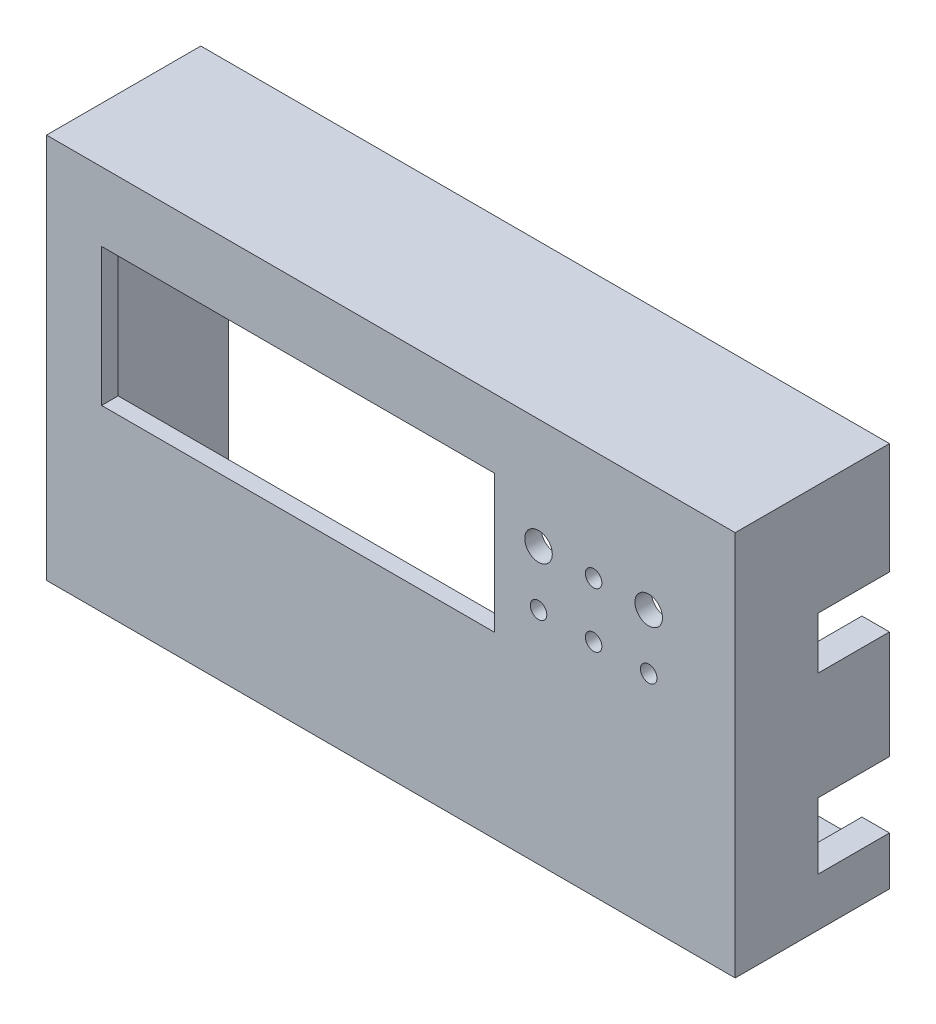
from build123d import *

# Parameters (mm, degrees)
SKETCH1_W           = 125
SKETCH1_H           = 70
BOSS_EXTRUDE1_DEPTH = 3
SKETCH2_W           = 71.3
SKETCH2_H           = 25
CUT_EXTRUDE1_DEPTH  = 5
SKETCH4_R           = 2.5
SKETCH4_R_2         = 1.5
CUT_EXTRUDE2_DEPTH  = 5
SKETCH5_W           = 125
SKETCH5_H           = 70
SKETCH5_W_2         = 115
SKETCH5_H_2         = 60
BOSS_EXTRUDE2_DEPTH = 25
SKETCH6_R           = 2
CUT_EXTRUDE3_DEPTH  = 10
SKETCH7_W           = 13
SKETCH7_H           = 12
SKETCH7_H_2         = 9.422573881
CUT_EXTRUDE4_DEPTH  = 10


with BuildPart() as part:
    # Sketch1 → Boss-Extrude1 (new body)
    with BuildSketch(Plane.XY):
        with Locations((62.5, 35)):
            Rectangle(SKETCH1_W, SKETCH1_H)
    extrude(amount=BOSS_EXTRUDE1_DEPTH)

    # Sketch2 → Cut-Extrude1 (cut)
    with BuildSketch(Plane.XY.offset(3)):
        with Locations((45.65, 45)):
            Rectangle(SKETCH2_W, SKETCH2_H)
    extrude(amount=-CUT_EXTRUDE1_DEPTH, mode=Mode.SUBTRACT)

    # Sketch4 → Cut-Extrude2 (cut)
    with BuildSketch(Plane.XY.offset(3)):
        with Locations((89.3, 50)):
            Circle(SKETCH4_R)
        with Locations((99.3, 50)):
            Circle(SKETCH4_R_2)
        with Locations((109.3, 50)):
            Circle(SKETCH4_R)
        with Locations((89.3, 40)):
            Circle(SKETCH4_R_2)
        with Locations((99.3, 40)):
            Circle(SKETCH4_R_2)
        with Locations((109.3, 40)):
            Circle(SKETCH4_R_2)
    extrude(amount=-CUT_EXTRUDE2_DEPTH, mode=Mode.SUBTRACT)

    # Sketch5 → Boss-Extrude2 (add)
    with BuildSketch(Plane(origin=(0, 0, 0), x_dir=(-1, 0, 0), z_dir=(0, 0, -1))):
        with Locations((-62.5, 35)):
            Rectangle(SKETCH5_W, SKETCH5_H)
        with Locations((-62.5, 35)):
            Rectangle(SKETCH5_W_2, SKETCH5_H_2, mode=Mode.SUBTRACT)
    extrude(amount=BOSS_EXTRUDE2_DEPTH)

    # Sketch6 → Cut-Extrude3 (cut)
    with BuildSketch(Plane(origin=(0, 0, -25), x_dir=(-1, 0, 0), z_dir=(0, 0, -1))):
        with Locations((-122.5, 67.5)):
            Circle(SKETCH6_R)
        with Locations((-2.5, 67.5)):
            Circle(SKETCH6_R)
        with Locations((-2.5, 2.5)):
            Circle(SKETCH6_R)
        with Locations((-122.5, 2.5)):
            Circle(SKETCH6_R)
    extrude(amount=-CUT_EXTRUDE3_DEPTH, mode=Mode.SUBTRACT)

    # Sketch7 → Cut-Extrude4 (cut)
    with BuildSketch(Plane(origin=(125, 0, 0), x_dir=(0, 0, -1), z_dir=(1, 0, 0))):
        with Locations((18.5, 14.8)):
            Rectangle(SKETCH7_W, SKETCH7_H)
        with Locations((18.5, 45.111286941)):
            Rectangle(SKETCH7_W, SKETCH7_H_2)
    extrude(amount=-CUT_EXTRUDE4_DEPTH, mode=Mode.SUBTRACT)


solid = part.part
